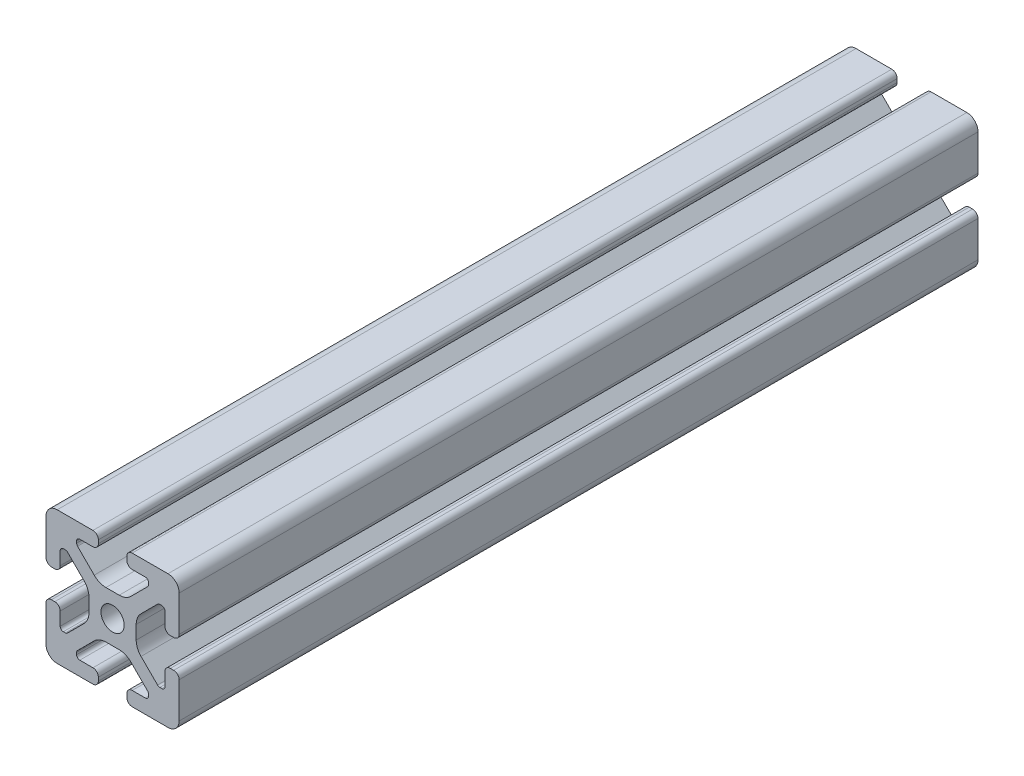
from build123d import *

# Parameters (mm, degrees)
SKETCH1_R           = 3.3274
BOSS_EXTRUDE1_DEPTH = 114.3


with BuildPart() as part:
    # Sketch1 → Boss-Extrude1 (new body, symmetric)
    with BuildSketch(Plane.XY):
        with BuildLine():
            Line((-4.064, 16.539617552), (-4.064, 17.496382454))
            ThreePointArc((-4.064, 17.496382454), (-4.519044044, 18.594955958), (-5.617617547, 19.050000004))
            Line((-5.617617547, 19.050000004), (-15.84748704, 19.050000004))
            ThreePointArc((-15.84748704, 19.050000004), (-18.12017629, 18.120192086), (-19.050000001, 15.847509297))
            Line((-19.050000001, 15.847509297), (-19.050000001, 5.617617549))
            ThreePointArc((-19.050000001, 5.617617549), (-18.594955957, 4.519044045), (-17.496382454, 4.064))
            Line((-17.496382454, 4.064), (-16.539617549, 4.064))
            ThreePointArc((-16.539617549, 4.064), (-15.441044044, 4.519044045), (-14.986, 5.617617549))
            Line((-14.986, 5.617617549), (-14.986, 9.385342517))
            ThreePointArc((-14.986, 9.385342517), (-14.721898184, 10.022940701), (-14.0843, 10.287042517))
            Line((-14.0843, 10.287042517), (-13.516042086, 10.287042517))
            ThreePointArc((-13.516042086, 10.287042517), (-13.170975923, 10.218404479), (-12.878443117, 10.022939917))
            Line((-12.878443117, 10.022939917), (-8.14758008, 5.292065242))
            ThreePointArc((-8.14758008, 5.292065242), (-7.117955877, 3.751120652), (-6.756399998, 1.933453582))
            Line((-6.756399998, 1.933453582), (-6.756399998, -1.933453584))
            ThreePointArc((-6.756399998, -1.933453584), (-7.117955877, -3.751120652), (-8.147580078, -5.292065242))
            Line((-8.147580078, -5.292065242), (-12.878443116, -10.022939917))
            ThreePointArc((-12.878443116, -10.022939917), (-13.170975922, -10.21840448), (-13.516042086, -10.287042518))
            Line((-13.516042086, -10.287042518), (-14.0843, -10.287042518))
            ThreePointArc((-14.0843, -10.287042518), (-14.721898185, -10.022940703), (-14.986, -9.385342518))
            Line((-14.986, -9.385342518), (-14.986, -5.617617549))
            ThreePointArc((-14.986, -5.617617549), (-15.441044044, -4.519044046), (-16.539617547, -4.064))
            Line((-16.539617547, -4.064), (-17.496382452, -4.064))
            ThreePointArc((-17.496382452, -4.064), (-18.594955956, -4.519044044), (-19.050000001, -5.617617547))
            Line((-19.050000001, -5.617617547), (-19.050000001, -15.84751072))
            ThreePointArc((-19.050000001, -15.84751072), (-18.120175718, -18.120192644), (-15.84748687, -19.050000001))
            Line((-15.84748687, -19.050000001), (-5.617617549, -19.050000001))
            ThreePointArc((-5.617617549, -19.050000001), (-4.519044046, -18.594955957), (-4.064, -17.496382454))
            Line((-4.064, -17.496382454), (-4.064, -16.539617549))
            ThreePointArc((-4.064, -16.539617549), (-4.519044045, -15.441044044), (-5.617617549, -14.985999999))
            Line((-5.617617549, -14.985999999), (-9.3853, -14.985999999))
            ThreePointArc((-9.3853, -14.985999999), (-10.022898185, -14.721898184), (-10.287, -14.084299999))
            Line((-10.287, -14.084299999), (-10.287, -13.552357131))
            ThreePointArc((-10.287, -13.552357131), (-10.218362387, -13.207291993), (-10.022898969, -12.914759731))
            Line((-10.022898969, -12.914759731), (-5.252158104, -8.14400713))
            ThreePointArc((-5.252158104, -8.14400713), (-3.715177371, -7.117027388), (-1.902183976, -6.7564))
            Line((-1.902183976, -6.7564), (1.902183976, -6.7564))
            ThreePointArc((1.902183976, -6.7564), (3.715177372, -7.117027388), (5.252158106, -8.144007132))
            Line((5.252158106, -8.144007132), (10.022898969, -12.91475973))
            ThreePointArc((10.022898969, -12.91475973), (10.218362387, -13.207291993), (10.287000001, -13.552357132))
            Line((10.287000001, -13.552357132), (10.287000001, -14.0843))
            ThreePointArc((10.287000001, -14.0843), (10.022898185, -14.721898184), (9.385300001, -14.986))
            Line((9.385300001, -14.986), (5.617617549, -14.986))
            ThreePointArc((5.617617549, -14.986), (4.519044045, -15.441044044), (4.064, -16.539617547))
            Line((4.064, -16.539617547), (4.064, -17.496382452))
            ThreePointArc((4.064, -17.496382452), (4.519044043, -18.594955955), (5.617617546, -19.050000001))
            Line((5.617617546, -19.050000001), (15.847486867, -19.050000001))
            ThreePointArc((15.847486867, -19.050000001), (18.120175716, -18.120192646), (19.05, -15.847510723))
            Line((19.05, -15.847510723), (19.05, -5.617617549))
            ThreePointArc((19.05, -5.617617549), (18.594955955, -4.519044045), (17.496382451, -4.064))
            Line((17.496382451, -4.064), (16.539617548, -4.064))
            ThreePointArc((16.539617548, -4.064), (15.441044044, -4.519044045), (14.985999999, -5.617617549))
            Line((14.985999999, -5.617617549), (14.985999999, -9.385342517))
            ThreePointArc((14.985999999, -9.385342517), (14.721898184, -10.022940701), (14.084299999, -10.287042517))
            Line((14.084299999, -10.287042517), (13.516042085, -10.287042517))
            ThreePointArc((13.516042085, -10.287042517), (13.170975922, -10.218404479), (12.878443117, -10.022939917))
            Line((12.878443117, -10.022939917), (8.147580079, -5.292065242))
            ThreePointArc((8.147580079, -5.292065242), (7.117955877, -3.751120652), (6.756399998, -1.933453583))
            Line((6.756399998, -1.933453583), (6.756399998, 1.933453583))
            ThreePointArc((6.756399998, 1.933453583), (7.117955877, 3.751120652), (8.147580078, 5.292065242))
            Line((8.147580078, 5.292065242), (12.878443116, 10.022939916))
            ThreePointArc((12.878443116, 10.022939916), (13.170975922, 10.218404477), (13.516042084, 10.287042515))
            Line((13.516042084, 10.287042515), (14.084299998, 10.287042515))
            ThreePointArc((14.084299998, 10.287042515), (14.721898183, 10.0229407), (14.985999998, 9.385342515))
            Line((14.985999998, 9.385342515), (14.985999998, 5.617617546))
            ThreePointArc((14.985999998, 5.617617546), (15.441044043, 4.519044042), (16.539617547, 4.063999997))
            Line((16.539617547, 4.063999997), (17.49638245, 4.063999997))
            ThreePointArc((17.49638245, 4.063999997), (18.594955956, 4.519044042), (19.05, 5.617617548))
            Line((19.05, 5.617617548), (19.05, 15.8475093))
            ThreePointArc((19.05, 15.8475093), (18.120176289, 18.120192086), (15.847487041, 19.050000004))
            Line((15.847487041, 19.050000004), (5.617617548, 19.050000004))
            ThreePointArc((5.617617548, 19.050000004), (4.519044044, 18.594955959), (4.063999999, 17.496382454))
            Line((4.063999999, 17.496382454), (4.063999999, 16.539617552))
            ThreePointArc((4.063999999, 16.539617552), (4.519044044, 15.441044047), (5.617617548, 14.986000002))
            Line((5.617617548, 14.986000002), (9.385299999, 14.986000002))
            ThreePointArc((9.385299999, 14.986000002), (10.022898183, 14.721898187), (10.286999999, 14.084300002))
            Line((10.286999999, 14.084300002), (10.286999999, 13.552357134))
            ThreePointArc((10.286999999, 13.552357134), (10.218362386, 13.207291996), (10.022898968, 12.914759734))
            Line((10.022898968, 12.914759734), (5.252158103, 8.144007133))
            ThreePointArc((5.252158103, 8.144007133), (3.71517737, 7.117027391), (1.902183975, 6.756400003))
            Line((1.902183975, 6.756400003), (-1.902183977, 6.756400003))
            ThreePointArc((-1.902183977, 6.756400003), (-3.715177373, 7.117027391), (-5.252158106, 8.144007134))
            Line((-5.252158106, 8.144007134), (-10.022898969, 12.914759733))
            ThreePointArc((-10.022898969, 12.914759733), (-10.218362387, 13.207291995), (-10.287000001, 13.552357134))
            Line((-10.287000001, 13.552357134), (-10.287000001, 14.084300002))
            ThreePointArc((-10.287000001, 14.084300002), (-10.022898186, 14.721898187), (-9.385300001, 14.986000002))
            Line((-9.385300001, 14.986000002), (-5.617617549, 14.986000002))
            ThreePointArc((-5.617617549, 14.986000002), (-4.519044044, 15.441044047), (-4.064, 16.539617552))
        make_face()
        Circle(SKETCH1_R, mode=Mode.SUBTRACT)
    extrude(amount=BOSS_EXTRUDE1_DEPTH, both=True)


solid = part.part
